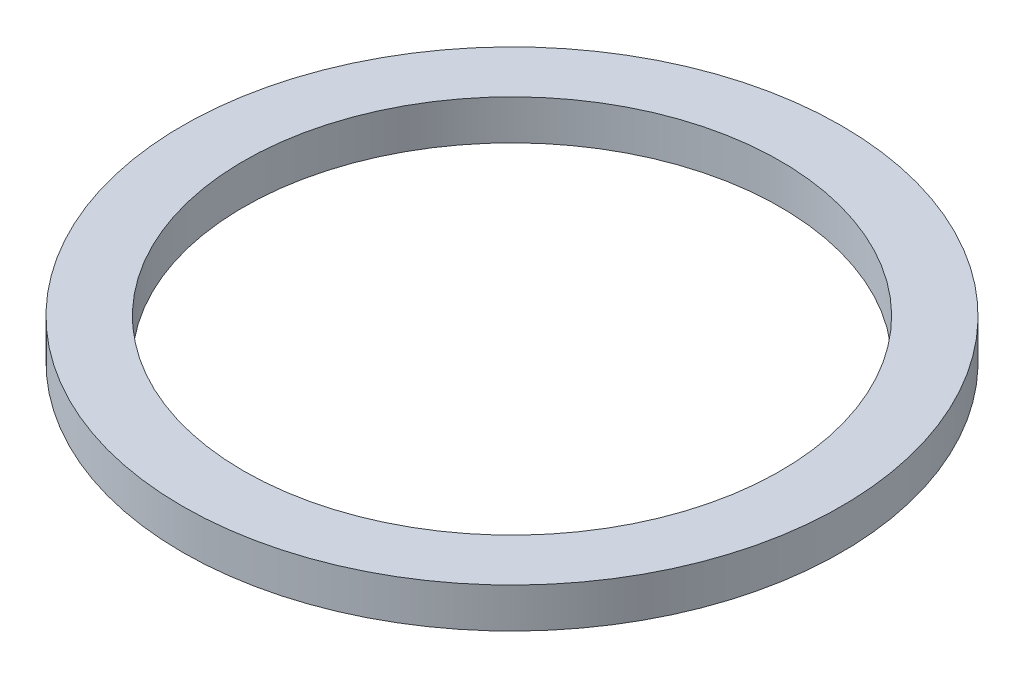
from build123d import *

# Parameters (mm, degrees)
SKETCH1_R           = 78.74
SKETCH1_R_2         = 64.135
BOSS_EXTRUDE1_DEPTH = 9.525


with BuildPart() as part:
    # Sketch1 → Boss-Extrude1 (new body)
    with BuildSketch(Plane(origin=(0, 0, 0), x_dir=(1, 0, 0), z_dir=(0, 1, 0))):
        Circle(SKETCH1_R)
        Circle(SKETCH1_R_2, mode=Mode.SUBTRACT)
    extrude(amount=BOSS_EXTRUDE1_DEPTH)


solid = part.part
